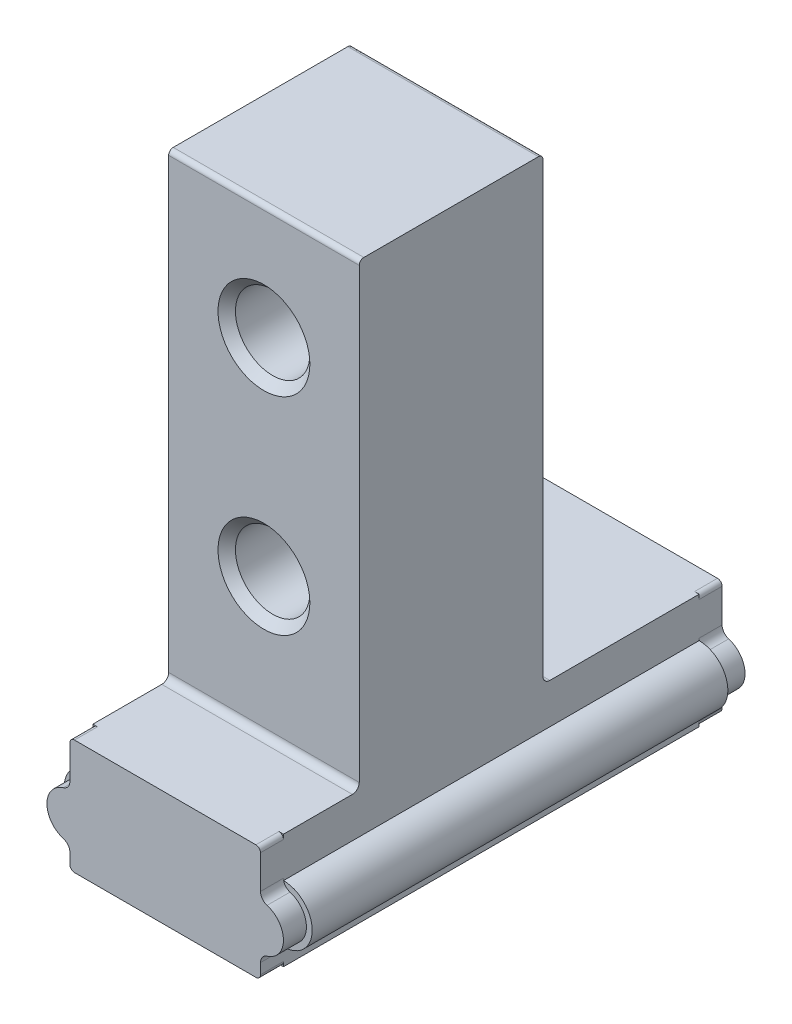
from build123d import *

# Parameters (mm, degrees)
BOSS_EXTRUDE1_DEPTH      = 4.15
BOSS_EXTRUDE1_DEPTH_BACK = 4.15
BOSS_EXTRUDE2_DEPTH      = 18.1
BOSS_EXTRUDE3_DEPTH      = 1
BOSS_EXTRUDE4_START      = 1
BOSS_EXTRUDE4_DEPTH      = 1
BOSS_EXTRUDE5_DEPTH      = 1
BOSS_EXTRUDE5_DEPTH_BACK = 1
SKETCH7_W                = 2
SKETCH7_H                = 2


with BuildPart() as part:
    # Sketch1 → Boss-Extrude1 (new, two sides: drawn at the far end of the back side and taken through both)
    with BuildSketch(Plane(origin=(0, 0, 0), x_dir=(0, 0, -1), z_dir=(1, 0, 0)).offset(-BOSS_EXTRUDE1_DEPTH_BACK)):
        with BuildLine():
            Line((-18.1, 5), (-18.1, 0))
            Line((-18.1, 0), (0, 0))
            Line((0, 0), (0, 5))
            Line((0, 5), (-6.5, 5))
            ThreePointArc((-6.5, 5), (-6.712132034, 5.087867966), (-6.8, 5.3))
            Line((-6.8, 5.3), (-6.8, 24.8))
            ThreePointArc((-6.8, 24.8), (-6.858578644, 24.941421356), (-7, 25))
            Line((-7, 25), (-14.6, 25))
            ThreePointArc((-14.6, 25), (-14.741421356, 24.941421356), (-14.8, 24.8))
            Line((-14.8, 24.8), (-14.8, 5.3))
            ThreePointArc((-14.8, 5.3), (-14.887867966, 5.087867966), (-15.1, 5))
            Line((-15.1, 5), (-18.1, 5))
        make_face()
    extrude(amount=BOSS_EXTRUDE1_DEPTH + BOSS_EXTRUDE1_DEPTH_BACK)

    # Sketch2 → Cut-Revolve1 (revolve, cut)
    with BuildSketch(Plane(origin=(0, 0, 0), x_dir=(0, 0, -1), z_dir=(1, 0, 0))):
        Polygon((-14.8, 20), (-14.8, 22), (-14.421, 21.621), (-7.179, 21.621), (-6.8, 22), (-6.8, 20), align=None)
    revolve(axis=Axis((0, 20, 6.8), (0, 0, 1)), mode=Mode.SUBTRACT)

    # Sketch3 → Cut-Revolve2 (revolve, cut)
    with BuildSketch(Plane(origin=(0, 0, 0), x_dir=(0, 0, -1), z_dir=(1, 0, 0))):
        Polygon((-14.8, 11), (-14.8, 13), (-14.421, 12.621), (-7.179, 12.621), (-6.8, 13), (-6.8, 11), align=None)
    revolve(axis=Axis((0, 11, 6.8), (0, 0, 1)), mode=Mode.SUBTRACT)

    # Sketch4 → Boss-Extrude2 (add)
    with BuildSketch(Plane.XY):
        with BuildLine():
            Line((-4.15, 0.75), (4.15, 0.75))
            ThreePointArc((4.15, 0.75), (5.4, 2), (4.15, 3.25))
            Line((4.15, 3.25), (-4.15, 3.25))
            ThreePointArc((-4.15, 3.25), (-5.4, 2), (-4.15, 0.75))
        make_face()
    extrude(amount=BOSS_EXTRUDE2_DEPTH)

    # Sketch5 → Boss-Extrude3 (add)
    with BuildSketch(Plane.XY):
        with BuildLine():
            Line((-4.15, 0.658359214), (-4.15, 0.2))
            ThreePointArc((-4.15, 0.2), (-4.091421356, 0.058578644), (-3.95, 0))
            Line((-3.95, 0), (3.95, 0))
            ThreePointArc((3.95, 0), (4.091421356, 0.058578644), (4.15, 0.2))
            Line((4.15, 0.2), (4.15, 0.658359214))
            ThreePointArc((4.15, 0.658359214), (4.22928651, 0.897404935), (4.435714286, 1.041685153))
            ThreePointArc((4.435714286, 1.041685153), (5.15, 2), (4.435714286, 2.958314847))
            ThreePointArc((4.435714286, 2.958314847), (4.22928651, 3.102595065), (4.15, 3.341640786))
            Line((4.15, 3.341640786), (4.15, 4.8))
            ThreePointArc((4.15, 4.8), (4.091421356, 4.941421356), (3.95, 5))
            Line((3.95, 5), (-3.95, 5))
            ThreePointArc((-3.95, 5), (-4.091421356, 4.941421356), (-4.15, 4.8))
            Line((-4.15, 4.8), (-4.15, 3.341640786))
            ThreePointArc((-4.15, 3.341640786), (-4.22928651, 3.102595065), (-4.435714286, 2.958314847))
            ThreePointArc((-4.435714286, 2.958314847), (-5.15, 2), (-4.435714286, 1.041685153))
            ThreePointArc((-4.435714286, 1.041685153), (-4.22928651, 0.897404935), (-4.15, 0.658359214))
        make_face()
    extrude(amount=-BOSS_EXTRUDE3_DEPTH)

    # Sketch6 → Boss-Extrude4 (add)
    with BuildSketch(Plane.XY.offset(18.1).offset(BOSS_EXTRUDE4_START)):
        with BuildLine():
            Line((-4.15, 0.658359214), (-4.15, 0.2))
            ThreePointArc((-4.15, 0.2), (-4.091421356, 0.058578644), (-3.95, 0))
            Line((-3.95, 0), (3.95, 0))
            ThreePointArc((3.95, 0), (4.091421356, 0.058578644), (4.15, 0.2))
            Line((4.15, 0.2), (4.15, 0.658359214))
            ThreePointArc((4.15, 0.658359214), (4.22928651, 0.897404935), (4.435714286, 1.041685153))
            ThreePointArc((4.435714286, 1.041685153), (5.15, 2), (4.435714286, 2.958314847))
            ThreePointArc((4.435714286, 2.958314847), (4.22928651, 3.102595065), (4.15, 3.341640786))
            Line((4.15, 3.341640786), (4.15, 4.8))
            ThreePointArc((4.15, 4.8), (4.091421356, 4.941421356), (3.95, 5))
            Line((3.95, 5), (-3.95, 5))
            ThreePointArc((-3.95, 5), (-4.091421356, 4.941421356), (-4.15, 4.8))
            Line((-4.15, 4.8), (-4.15, 3.341640786))
            ThreePointArc((-4.15, 3.341640786), (-4.22928651, 3.102595065), (-4.435714286, 2.958314847))
            ThreePointArc((-4.435714286, 2.958314847), (-5.15, 2), (-4.435714286, 1.041685153))
            ThreePointArc((-4.435714286, 1.041685153), (-4.22928651, 0.897404935), (-4.15, 0.658359214))
        make_face()
    extrude(amount=-BOSS_EXTRUDE4_DEPTH)

    # Sketch7 → Boss-Extrude5 (add, two sides: drawn at the far end of the back side and taken through both)
    with BuildSketch(Plane(origin=(0, 0, 0), x_dir=(0, 0, -1), z_dir=(1, 0, 0)).offset(-BOSS_EXTRUDE5_DEPTH_BACK)):
        with Locations((-3, -1)):
            Rectangle(SKETCH7_W, SKETCH7_H)
    extrude(amount=BOSS_EXTRUDE5_DEPTH + BOSS_EXTRUDE5_DEPTH_BACK)


solid = part.part
